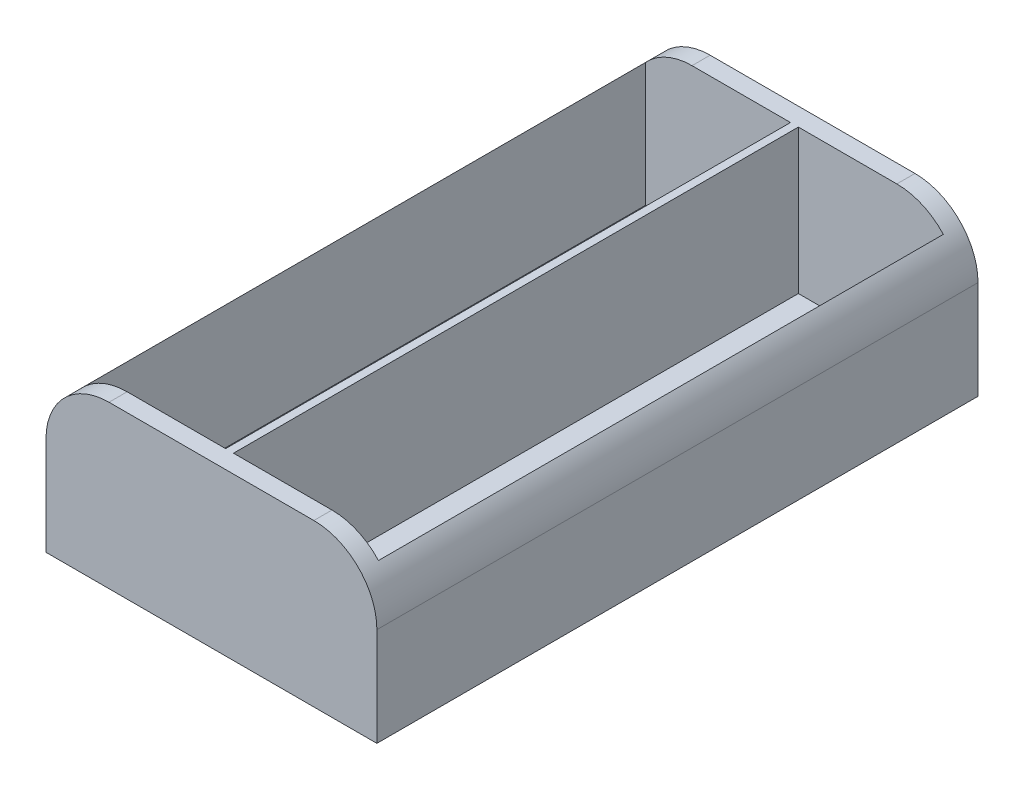
from build123d import *

# Parameters (mm, degrees)
SKETCH_1_W          = 42
SKETCH_1_H          = 76.3
EXTRUDE_1_DEPTH     = 20.5
FILLET_1_R          = 8
SHELL_1_T           = 2.3
CUT_EXTRUDE_START   = 2.2
SKETCH_3_W          = 37.8
SKETCH_3_H          = 71.7
CUT_EXTRUDE_1_DEPTH = 46.931824191
SKETCH_1_3_R        = 1.5
CUT_EXTRUDE_2_DEPTH = 49.131824191
SKETCH_4_W          = 1
SKETCH_4_H          = 76.3
EXTRUDE_2_DEPTH     = 20.5
CHAMFER1_SIZE       = 1.3


with BuildPart() as part:
    # Эскиз1 → Бобышка-Вытянуть1 (new body)
    with BuildSketch(Plane(origin=(0, 0, 0), x_dir=(1, 0, 0), z_dir=(0, 1, 0))):
        Rectangle(SKETCH_1_W, SKETCH_1_H)
    extrude(amount=EXTRUDE_1_DEPTH)

    # Скругление1
    fillet_1_edges = [part.edges().sort_by_distance(p)[0] for p in [
        (-21, 20.5, 0),
        (21, 20.5, 0),
    ]]
    fillet(fillet_1_edges, radius=FILLET_1_R)

    # Оболочка1 (no face opened: a closed hollow body)
    add(offset(amount=-SHELL_1_T, mode=Mode.PRIVATE), mode=Mode.SUBTRACT)

    # Эскиз3 → Вырез-Вытянуть1 (cut, through all)
    with BuildSketch(Plane(origin=(0, 0, 0), x_dir=(1, 0, 0), z_dir=(0, 1, 0)).offset(CUT_EXTRUDE_START)):
        Rectangle(SKETCH_3_W, SKETCH_3_H)
    extrude(amount=CUT_EXTRUDE_1_DEPTH, mode=Mode.SUBTRACT)

    # Эскиз1<3> → Вырез-Вытянуть2 (cut, through all)
    with BuildSketch(Plane(origin=(0, 0, 0), x_dir=(1, 0, 0), z_dir=(0, 1, 0))):
        with Locations((-10.5, 0)):
            Circle(SKETCH_1_3_R)
        with Locations((10.5, 0)):
            Circle(SKETCH_1_3_R)
    extrude(amount=CUT_EXTRUDE_2_DEPTH, mode=Mode.SUBTRACT)

    # Эскиз4 → Бобышка-Вытянуть2 (add)
    with BuildSketch(Plane(origin=(0, 0, 0), x_dir=(1, 0, 0), z_dir=(0, 1, 0))):
        Rectangle(SKETCH_4_W, SKETCH_4_H)
    extrude(amount=EXTRUDE_2_DEPTH)

    # Chamfer1
    chamfer1_edges = [part.edges().sort_by_distance(p)[0] for p in [
        (9, 2.2, 0),
        (-12, 2.2, 0),
    ]]
    chamfer(chamfer1_edges, length=CHAMFER1_SIZE)


solid = part.part
